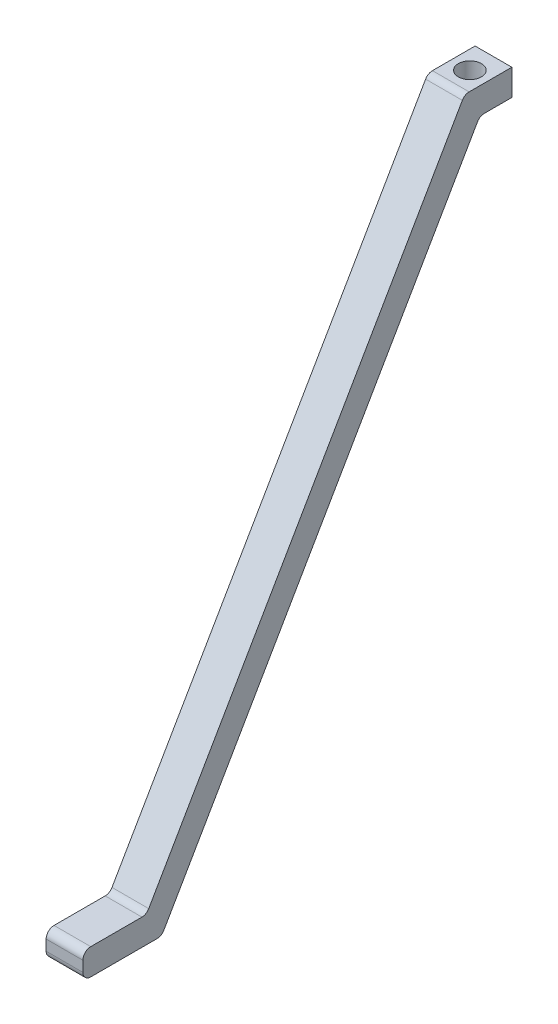
from build123d import *

# Parameters (mm, degrees)
SKETCH_1_W          = 7
SKETCH_1_H          = 9
EXTRUDE_1_DEPTH     = 10
SKETCH_2_R          = 2.2
CUT_EXTRUDE_1_DEPTH = 10
EXTRUDE_2_DEPTH     = 7
CUT_EXTRUDE_2_DEPTH = 7
FILLET_2_R          = 1.5
FILLET_3_R          = 1.5
FILLET_4_R          = 1.5


with BuildPart() as part:
    # 草图1 → 凸台-拉伸1 (new body)
    with BuildSketch(Plane(origin=(0, 0, 0), x_dir=(1, 0, 0), z_dir=(0, 1, 0))):
        Rectangle(SKETCH_1_W, SKETCH_1_H)
    extrude(amount=EXTRUDE_1_DEPTH)

    # 草图2 → 切除-拉伸1 (cut)
    with BuildSketch(Plane(origin=(0, 10, 0), x_dir=(1, 0, 0), z_dir=(0, 1, 0))):
        Circle(SKETCH_2_R)
    extrude(amount=-CUT_EXTRUDE_1_DEPTH, mode=Mode.SUBTRACT)

    # 草图3 → 凸台-拉伸2 (add)
    with BuildSketch(Plane.ZY.offset(3.5)):
        Polygon((4.5, 10), (4.5, 0), (62.235026919, -100), (77.235026919, -100), (77.235026919, -95), (65.121778265, -95), align=None)
    extrude(amount=-EXTRUDE_2_DEPTH)

    # 草图4 → 切除-拉伸2 (cut)
    with BuildSketch(Plane.ZY.offset(3.5)):
        Polygon((4.5, 0), (1.613248654, 5), (-4.5, 5), (-4.5, 0), align=None)
    extrude(amount=-CUT_EXTRUDE_2_DEPTH, mode=Mode.SUBTRACT)

    # 圆角2
    fillet_2_edges = [part.edges().sort_by_distance(p)[0] for p in [
        (0, 10, 4.5),
    ]]
    fillet(fillet_2_edges, radius=FILLET_2_R)

    # 圆角3
    fillet_3_edges = [part.edges().sort_by_distance(p)[0] for p in [
        (2.497901862, 5, 1.613248654),
        (-2.497901862, 5, 1.613248654),
    ]]
    fillet(fillet_3_edges, radius=FILLET_3_R)

    # 圆角4
    fillet_4_edges = [part.edges().sort_by_distance(p)[0] for p in [
        (0, -100, 77.235026919),
        (0, -100, 62.235026919),
        (0, -95, 65.121778265),
        (0, -95, 77.235026919),
    ]]
    fillet(fillet_4_edges, radius=FILLET_4_R)


solid = part.part
